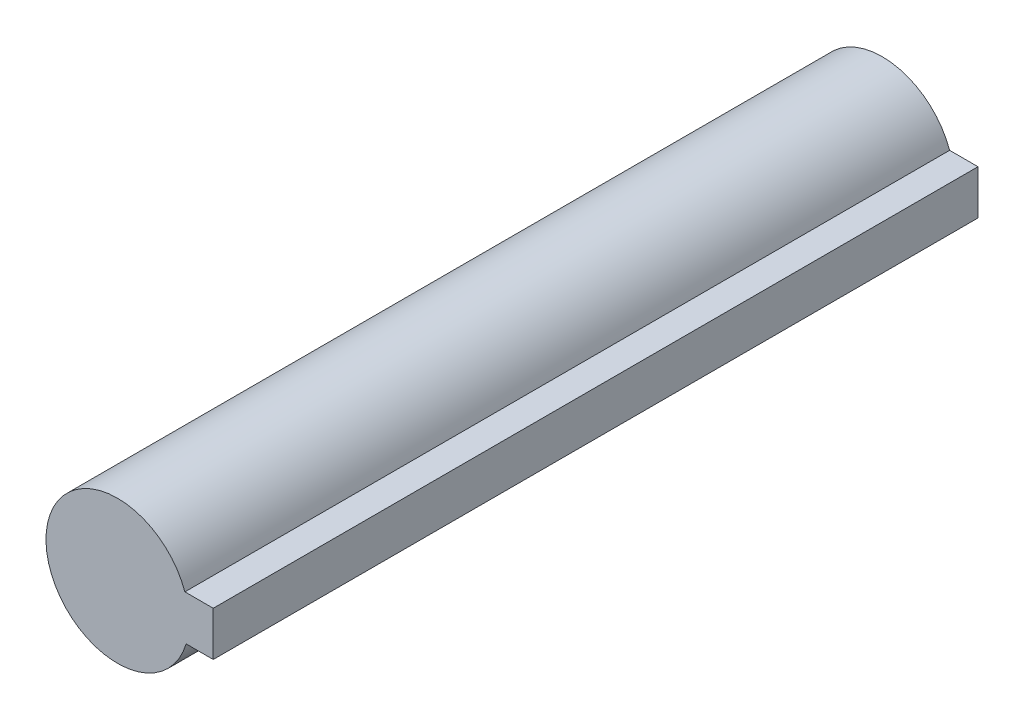
from build123d import *

# Parameters (mm, degrees)
BOSS_EXTRUDE1_DEPTH = 31


with BuildPart() as part:
    # Sketch1 → Boss-Extrude1 (new body)
    with BuildSketch(Plane(origin=(0, 0, 0), x_dir=(0, 1, 0), z_dir=(0, 0, 1))):
        with BuildLine():
            Line((-0.823454626, -2.780633467), (-0.823454626, -3.880633467))
            Line((-0.823454626, -3.880633467), (0.976545374, -3.880633467))
            Line((0.976545374, -3.880633467), (0.976545374, -2.730633467))
            ThreePointArc((0.976545374, -2.730633467), (-0.080524495, 2.89888182), (-0.823454626, -2.780633467))
        make_face()
    extrude(amount=BOSS_EXTRUDE1_DEPTH)


solid = part.part
